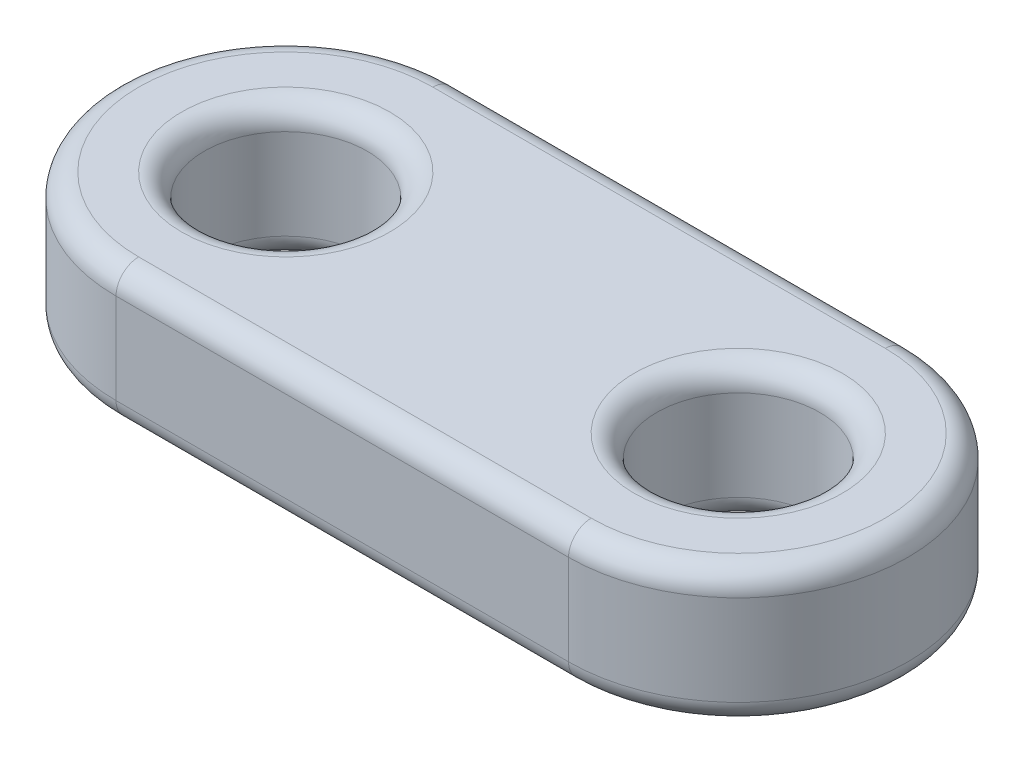
from build123d import *

# Parameters (mm, degrees)
BOSS_EXTRUDE1_DEPTH  = 3
M3_CLEARANCE_HOLE1_D = 3.6
FILLET1_R            = 0.5


with BuildPart() as part:
    # Sketch1 → Boss-Extrude1 (new body)
    with BuildSketch(Plane(origin=(0, 0, 0), x_dir=(1, 0, 0), z_dir=(0, 1, 0))):
        with BuildLine():
            Line((-5, 3.75), (5, 3.75))
            ThreePointArc((5, 3.75), (8.75, 0), (5, -3.75))
            Line((5, -3.75), (-5, -3.75))
            ThreePointArc((-5, -3.75), (-8.75, 0), (-5, 3.75))
        make_face()
    extrude(amount=BOSS_EXTRUDE1_DEPTH)

    # M3 Clearance Hole1 (through all)
    with Locations(Plane.XZ):
        with Locations((-5, 0), (5, 0)):
            Hole(M3_CLEARANCE_HOLE1_D / 2)

    # Fillet1
    fillet1_edges = [part.edges().sort_by_distance(p)[0] for p in [
        (8.75, 3, 0),
        (6.8, 0, 0),
        (6.8, 3, 0),
        (0, 3, -3.75),
        (-3.2, 0, 0),
        (-3.2, 3, 0),
        (-8.75, 3, 0),
        (0, 0, -3.75),
        (8.75, 0, 0),
        (0, 0, 3.75),
        (-8.75, 0, 0),
        (0, 3, 3.75),
    ]]
    fillet(fillet1_edges, radius=FILLET1_R)


solid = part.part
